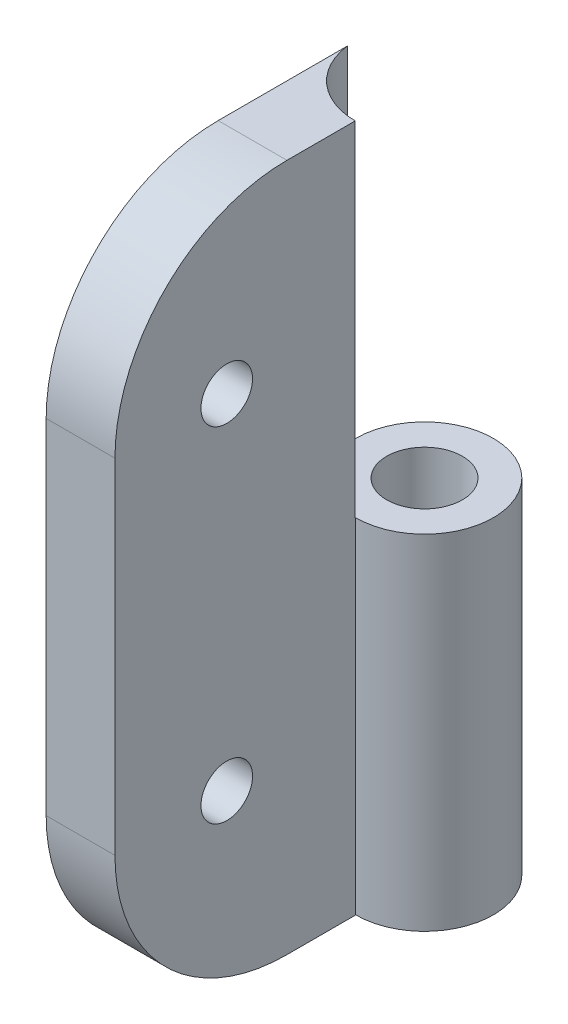
from build123d import *

# Parameters (mm, degrees)
SKETCH1_W           = 4
SKETCH1_H           = 40
EXTRUDE_THIN2_DEPTH = 18
SKETCH4_R           = 4
SKETCH7_R           = 2.2
CUT_EXTRUDE2_DEPTH  = 45.586993619
SKETCH8_R           = 4.03
CUT_EXTRUDE5_DEPTH  = 20
SKETCH9_R           = 1.5
CUT_EXTRUDE6_DEPTH  = 45.045431091
FILLET1_R           = 10


with BuildPart() as part:
    # Sketch1 → Extrude-Thin2 (new body)
    with BuildSketch(Plane.XY):
        with Locations((2, 20)):
            Rectangle(SKETCH1_W, SKETCH1_H)
    extrude(amount=EXTRUDE_THIN2_DEPTH)

    # Sweep3: sweep along a curve in space
    with BuildLine() as sweep3_path:
        Line((4, 0, 0), (4, 40, 0))
    # Sketch4 → Sweep3 (sweep)
    with BuildSketch(Plane(origin=(0, 40, 0), x_dir=(1, 0, 0), z_dir=(0, 1, 0))):
        with Locations((4, 0)):
            Circle(SKETCH4_R)
    sweep(path=sweep3_path.line)

    # Sketch7 → Cut-Extrude2 (cut, through all)
    with BuildSketch(Plane(origin=(0, 40, 0), x_dir=(1, 0, 0), z_dir=(0, 1, 0))):
        with Locations(Location((4, 0, 0), (0, 0, 270))):
            Circle(SKETCH7_R)
    extrude(amount=-CUT_EXTRUDE2_DEPTH, mode=Mode.SUBTRACT)

    # Sketch8 → Cut-Extrude5 (cut)
    with BuildSketch(Plane(origin=(0, 40, 0), x_dir=(1, 0, 0), z_dir=(0, 1, 0))):
        with Locations((4, 0)):
            Circle(SKETCH8_R)
    extrude(amount=-CUT_EXTRUDE5_DEPTH, mode=Mode.SUBTRACT)

    # Sketch9 → Cut-Extrude6 (cut, through all)
    with BuildSketch(Plane(origin=(4, 0, 0), x_dir=(0, 0, -1), z_dir=(1, 0, 0))):
        with Locations((-11.5, 10)):
            Circle(SKETCH9_R)
        with Locations((-11.5, 30)):
            Circle(SKETCH9_R)
    extrude(amount=-CUT_EXTRUDE6_DEPTH, mode=Mode.SUBTRACT)

    # Fillet1
    fillet1_edges = [part.edges().sort_by_distance(p)[0] for p in [
        (2, 0, 18),
        (2, 40, 18),
    ]]
    fillet(fillet1_edges, radius=FILLET1_R)


solid = part.part
